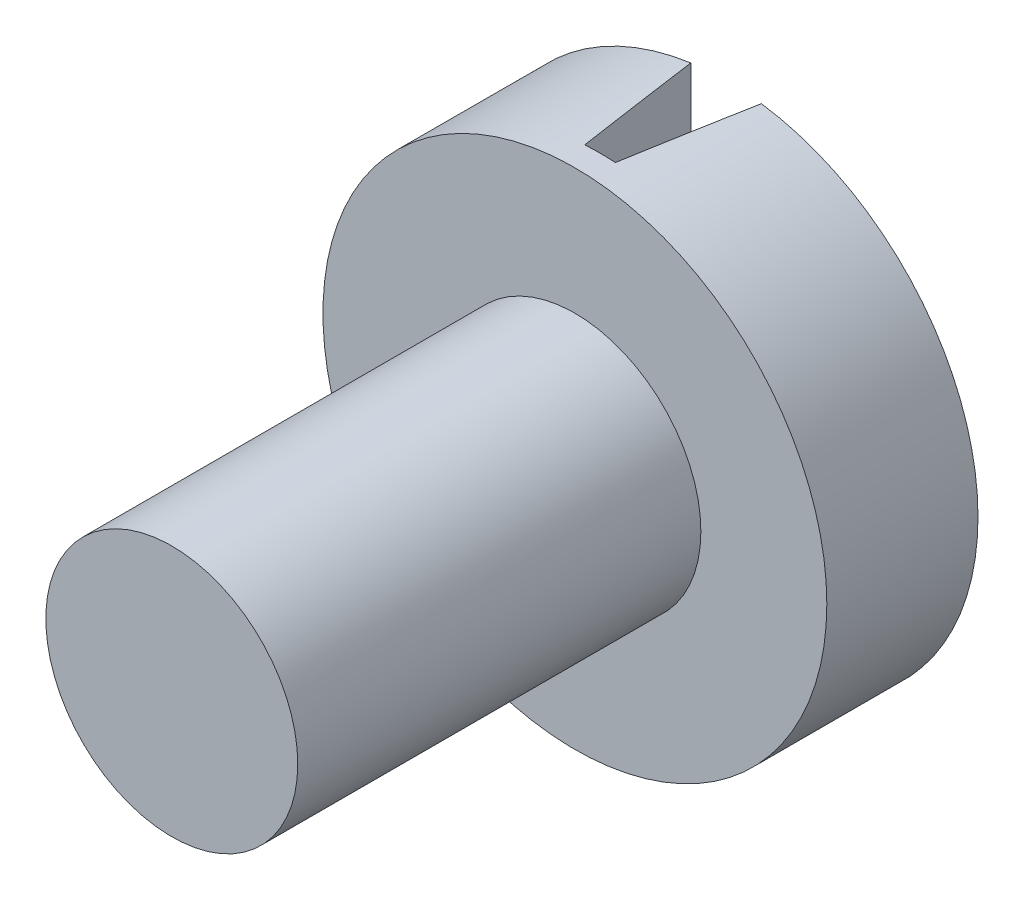
from build123d import *

# Parameters (mm, degrees)
CROQUIS1_R              = 2.5
SALIENTE_EXTRUIR1_DEPTH = 8
CROQUIS2_R              = 5
SALIENTE_EXTRUIR2_DEPTH = 3
CROQUIS3_W              = 1.4
CROQUIS3_H              = 11
CORTAR_EXTRUIR2_DEPTH   = 2.5
CORTAR_EXTRUIR2_TAPER   = 9


with BuildPart() as part:
    # Croquis1 → Saliente-Extruir1 (new body)
    with BuildSketch(Plane.XY):
        Circle(CROQUIS1_R)
    extrude(amount=SALIENTE_EXTRUIR1_DEPTH)

    # Croquis2 → Saliente-Extruir2 (add)
    with BuildSketch(Plane.XY):
        Circle(CROQUIS2_R)
    extrude(amount=-SALIENTE_EXTRUIR2_DEPTH)

    # Croquis3 → Cortar-Extruir2 (cut)
    with BuildSketch(Plane(origin=(0, 0, -3), x_dir=(-1, 0, 0), z_dir=(0, 0, -1))):
        Rectangle(CROQUIS3_W, CROQUIS3_H)
    extrude(amount=-CORTAR_EXTRUIR2_DEPTH, taper=CORTAR_EXTRUIR2_TAPER, mode=Mode.SUBTRACT)


solid = part.part
